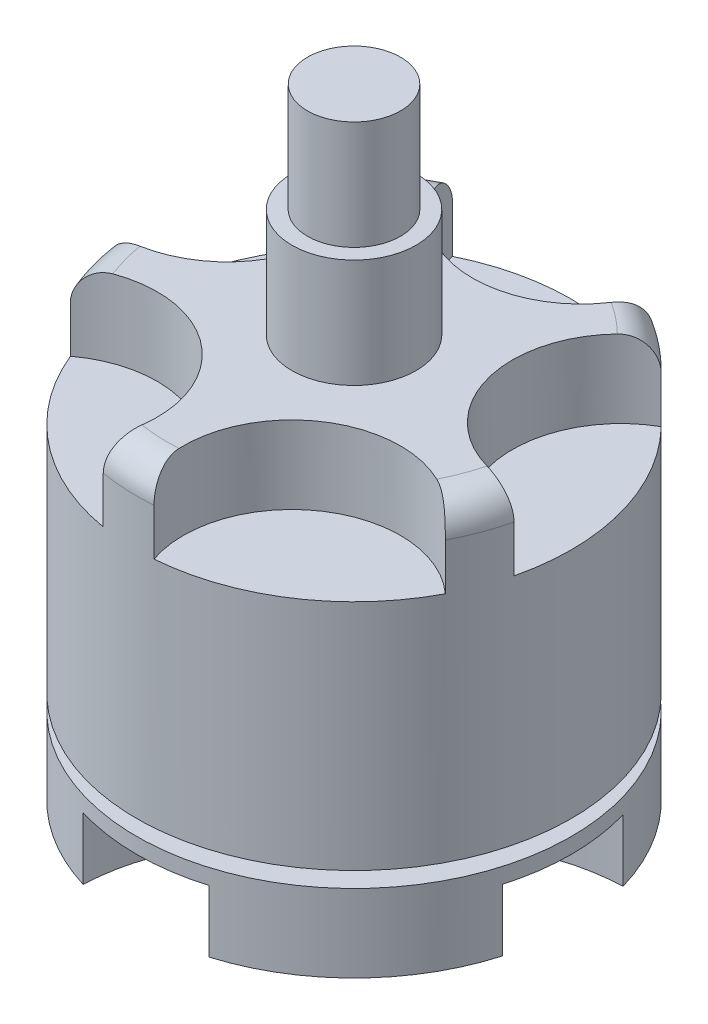
from build123d import *

# Parameters (mm, degrees)
SKETCH1_R           = 14
BOSS_EXTRUDE1_DEPTH = 26
SKETCH2_R           = 4
BOSS_EXTRUDE2_DEPTH = 7
SKETCH3_R           = 3
BOSS_EXTRUDE3_DEPTH = 7
SKETCH5_R           = 5
CUT_EXTRUDE1_DEPTH  = 5
SKETCH7_R           = 7
CUT_EXTRUDE2_DEPTH  = 5
FILLET1_R           = 2
SKETCH9_RX          = 7.5
SKETCH9_RY          = 4.068391424
SKETCH9_RY_2        = 3.899393896
CUT_EXTRUDE3_DEPTH  = 4
SKETCH11_R          = 14
SKETCH11_R_2        = 8
CUT_EXTRUDE4_DEPTH  = 1


with BuildPart() as part:
    # Sketch1 → Boss-Extrude1 (new body)
    with BuildSketch(Plane(origin=(0, 0, 0), x_dir=(1, 0, 0), z_dir=(0, 1, 0))):
        with Locations(Location((0, 0, 0), (0, 0, 90))):
            Circle(SKETCH1_R)
    extrude(amount=BOSS_EXTRUDE1_DEPTH)

    # Sketch2 → Boss-Extrude2 (add)
    with BuildSketch(Plane(origin=(0, 26, 0), x_dir=(1, 0, 0), z_dir=(0, 1, 0))):
        with Locations(Location((0, 0, 0), (0, 0, 270))):
            Circle(SKETCH2_R)
    extrude(amount=BOSS_EXTRUDE2_DEPTH)

    # Sketch3 → Boss-Extrude3 (add)
    with BuildSketch(Plane(origin=(0, 33, 0), x_dir=(1, 0, 0), z_dir=(0, 1, 0))):
        with Locations(Location((0, 0, 0), (0, 0, 270))):
            Circle(SKETCH3_R)
    extrude(amount=BOSS_EXTRUDE3_DEPTH)

    # Sketch5 → Cut-Extrude1 (cut)
    with BuildSketch(Plane.XZ):
        with Locations(Location((0, 0, 0), (0, 0, 270))):
            Circle(SKETCH5_R)
    extrude(amount=-CUT_EXTRUDE1_DEPTH, mode=Mode.SUBTRACT)

    # Sketch7 → Cut-Extrude2 (cut)
    with BuildSketch(Plane(origin=(0, 26, 0), x_dir=(1, 0, 0), z_dir=(0, 1, 0))):
        with Locations((-13.099617669, 4.939637327)):
            Circle(SKETCH7_R)
        with Locations((-8.745866262, -10.932054854)):
            Circle(SKETCH7_R)
        with Locations((7.694394058, -11.695995045)):
            Circle(SKETCH7_R)
        with Locations((13.501246597, 3.703557793)):
            Circle(SKETCH7_R)
        with Locations((0.649805899, 13.984911594)):
            Circle(SKETCH7_R)
    extrude(amount=-CUT_EXTRUDE2_DEPTH, mode=Mode.SUBTRACT)

    # Fillet1
    fillet1_edges = [part.edges().sort_by_distance(p)[0] for p in [
        (-13.501257172, 26, 3.703519243),
        (-0.64984583, 26, 13.984909739),
        (13.099631773, 26, 4.939599924),
        (8.745835048, 26, -10.932079826),
        (-7.694394058, 26, -11.695995045),
    ]]
    fillet(fillet1_edges, radius=FILLET1_R)

    # Sketch9 → Cut-Extrude3 (cut)
    with BuildSketch(Plane.XZ):
        with Locations(Location((0, -14), (0, 0, -90))):
            Ellipse(SKETCH9_RX, SKETCH9_RY)
        with Locations(Location((14, 0), (0, 0, 0))):
            Ellipse(SKETCH9_RX, SKETCH9_RY_2)
        with Locations(Location((0, 14), (0, 0, 90))):
            Ellipse(SKETCH9_RX, SKETCH9_RY)
        with BuildLine():
            ThreePointArc((-12.493901532, 6.31683659), (-14, 0), (-12.493901532, -6.31683659))
            add(Edge.make_bspline(
                [(-12.493901532, -6.31683659), (-7.506098468, 0), (-12.493901532, 6.31683659)],
                knots=[0, 0, 0, 1, 1, 1], degree=2))
        make_face()
    extrude(amount=-CUT_EXTRUDE3_DEPTH, mode=Mode.SUBTRACT)

    # Sketch11 → Cut-Extrude4 (cut)
    with BuildSketch(Plane(origin=(0, 5, 0), x_dir=(-1, 0, 0), z_dir=(0, -1, 0))):
        with Locations(Location((0, 0, 0), (0, 0, 90))):
            Circle(SKETCH11_R)
        with Locations(Location((0, 0, 0), (0, 0, 90))):
            Circle(SKETCH11_R_2, mode=Mode.SUBTRACT)
    extrude(amount=-CUT_EXTRUDE4_DEPTH, mode=Mode.SUBTRACT)


solid = part.part
